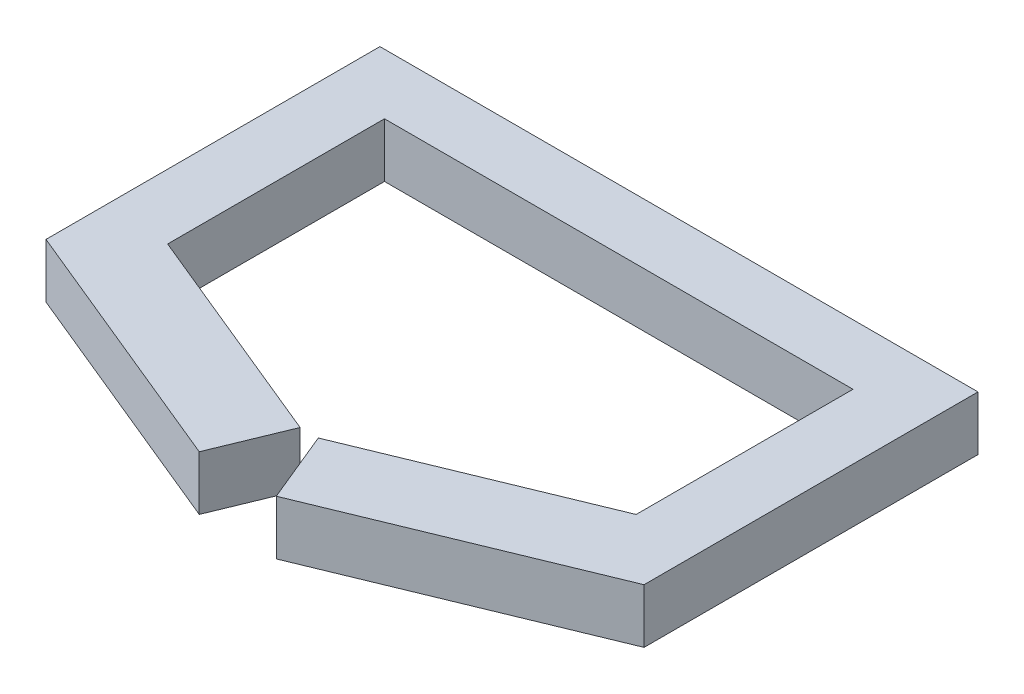
from build123d import *

# Parameters (mm, degrees)
BOSS_EXTRUDE1_DEPTH = 10


with BuildPart() as part:
    # Sketch1 → Boss-Extrude1 (new body)
    with BuildSketch(Plane(origin=(0, 0, 0), x_dir=(1, 0, 0), z_dir=(0, 1, 0))):
        Polygon((-7.091944581, -47.580500917), (-1.67627781, -34.42816733), (-43.13077302, -17.358669302), (-43.13077302, 22.565278213), (43.13077302, 22.565278213), (43.13077302, -17.358669302), (1.67627781, -34.42816733), (7.091944581, -47.580500917), (55.059278839, -27.829245634), (55.059278839, 33.654500648), (-55.059278839, 33.654500648), (-55.059278839, -27.829245634), align=None)
    extrude(amount=BOSS_EXTRUDE1_DEPTH)


solid = part.part
